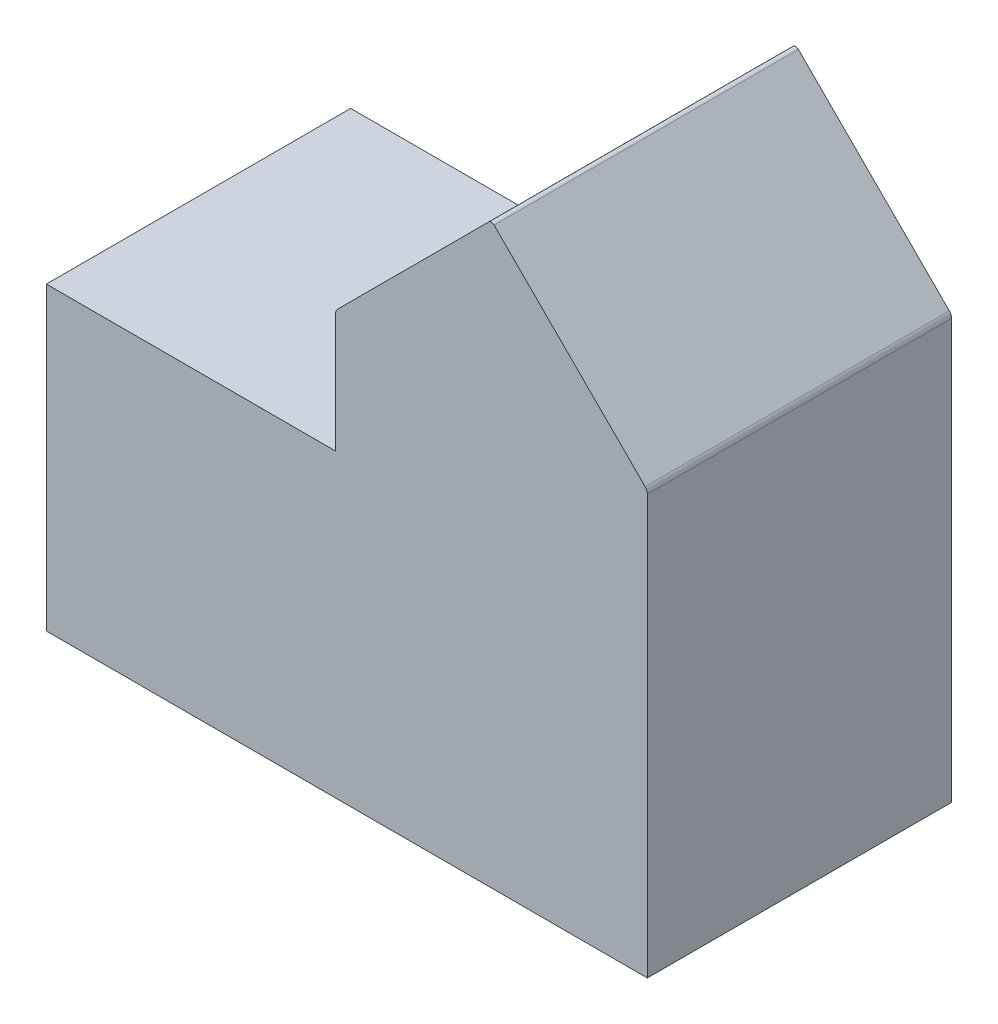
from build123d import *

# Parameters (mm, degrees)
SKETCH1_W           = 20.066
SKETCH1_H           = 10.033
BOSS_EXTRUDE1_DEPTH = 5.08
FILLET1_R           = 0.254
FILLET2_R           = 0.127


with BuildPart() as part:
    # Sketch1 → Boss-Extrude1 (new body, symmetric)
    with BuildSketch(Plane.XY):
        Polygon((-0.381, 5.0165), (10.033, 5.0165), (10.033, 9.0805), (4.826, 14.2875), (-0.381, 9.0805), align=None)
        Rectangle(SKETCH1_W, SKETCH1_H)
    extrude(amount=BOSS_EXTRUDE1_DEPTH, both=True)

    # Fillet1
    fillet1_edges = [part.edges().sort_by_distance(p)[0] for p in [
        (10.033, 9.0805, 0),
        (-0.381, 9.0805, 0),
    ]]
    fillet(fillet1_edges, radius=FILLET1_R)

    # Fillet2
    fillet2_edges = [part.edges().sort_by_distance(p)[0] for p in [
        (4.826, 14.2875, 0),
    ]]
    fillet(fillet2_edges, radius=FILLET2_R)


solid = part.part
